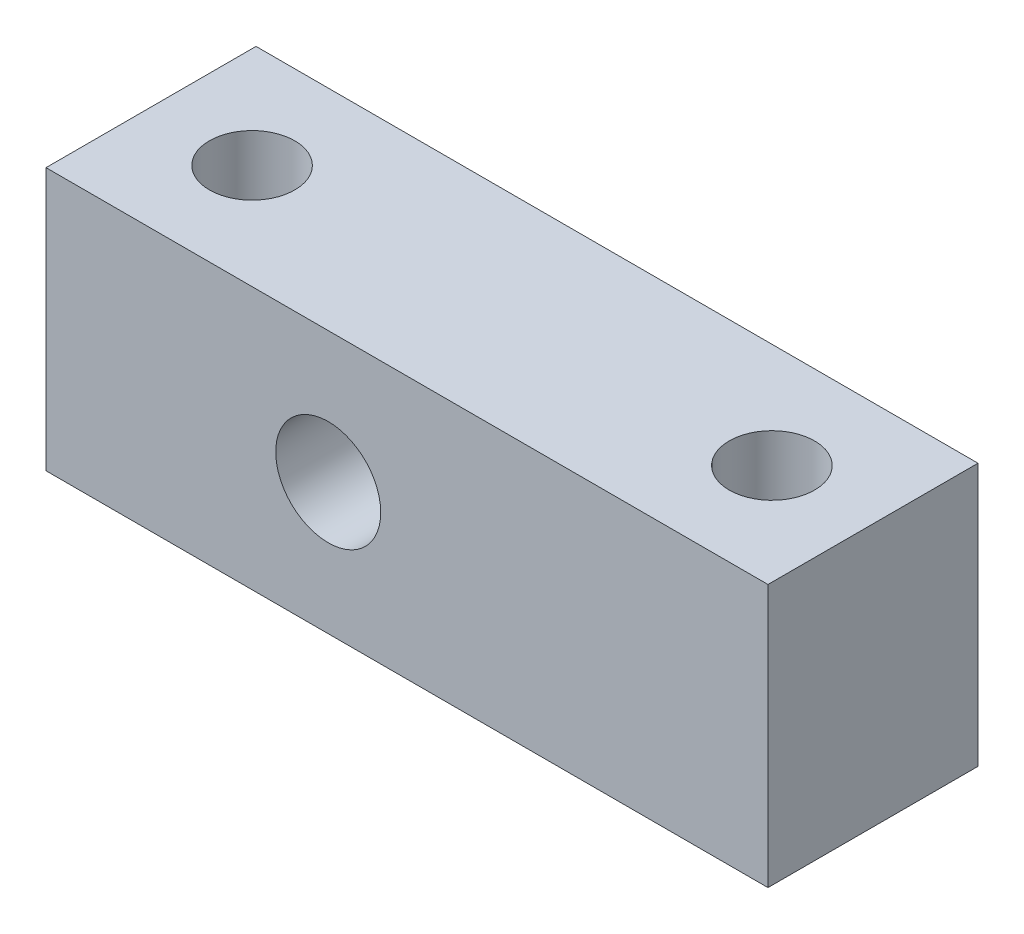
from build123d import *

# Parameters (mm, degrees)
SKETCH_1_W              = 55
SKETCH_1_H              = 20
EXTRUDE_1_DEPTH         = 16
SKETCH_2_R              = 4
CUT_EXTRUDE_1_DEPTH     = 18
HOLE_WIZARD_6_5_6_5_1_D = 6.5


with BuildPart() as part:
    # Эскиз1 → Бобышка-Вытянуть1 (new body)
    with BuildSketch(Plane.XY):
        Rectangle(SKETCH_1_W, SKETCH_1_H)
    extrude(amount=EXTRUDE_1_DEPTH)

    # Эскиз2 → Вырез-Вытянуть1 (cut)
    with BuildSketch(Plane.XY.offset(16)):
        with Locations((-6, 0)):
            Circle(SKETCH_2_R)
    extrude(amount=-CUT_EXTRUDE_1_DEPTH, mode=Mode.SUBTRACT)

    # Диаметр отверстия Ø6.5 (6.5)1 (through all)
    with Locations(Plane(origin=(0, 10, 0), x_dir=(1, 0, 0), z_dir=(0, 1, 0))):
        with Locations((19.8, -8), (-19.8, -8)):
            Hole(HOLE_WIZARD_6_5_6_5_1_D / 2)


solid = part.part
